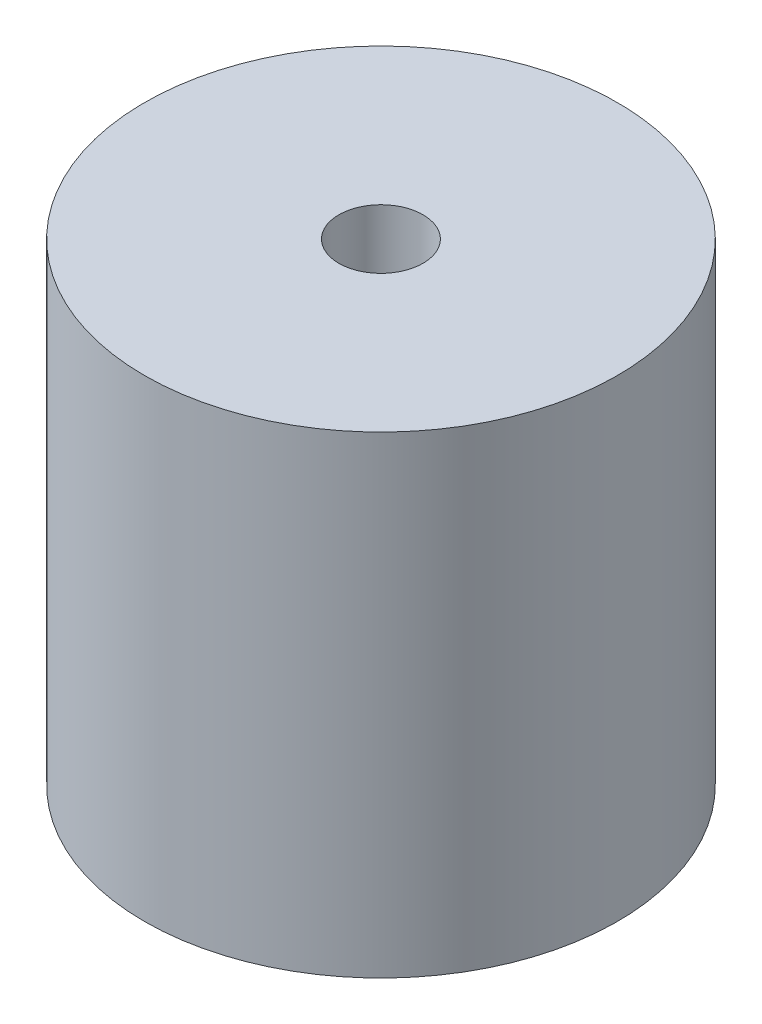
from build123d import *

# Parameters (mm, degrees)
SKETCH1_R                   = 6.35
BOSS_EXTRUDE1_DEPTH         = 12.7
F_4_40_TAPPED_HOLE1_D       = 2.2606
F_4_40_TAPPED_HOLE1_DEPTH   = 3.556
F_4_40_TAPPED_HOLE1_TIP     = 0.679152758
F_1_4_28_TAPPED_HOLE1_D     = 5.4102
F_1_4_28_TAPPED_HOLE1_DEPTH = 6
F_1_4_28_TAPPED_HOLE1_TIP   = 1.625388061


with BuildPart() as part:
    # Sketch1 → Boss-Extrude1 (new body)
    with BuildSketch(Plane(origin=(0, 0, 0), x_dir=(1, 0, 0), z_dir=(0, 1, 0))):
        Circle(SKETCH1_R)
    extrude(amount=BOSS_EXTRUDE1_DEPTH)

    # #4-40 Tapped Hole1
    with Locations(Plane(origin=(0, 12.7, 0), x_dir=(1, 0, 0), z_dir=(0, 1, 0))):
        with Locations((0, 0)):
            Hole(F_4_40_TAPPED_HOLE1_D / 2, depth=F_4_40_TAPPED_HOLE1_DEPTH)
            with Locations((0, 0, -(F_4_40_TAPPED_HOLE1_DEPTH + F_4_40_TAPPED_HOLE1_TIP / 2))):  # 118° drill point
                Cone(0, F_4_40_TAPPED_HOLE1_D / 2, F_4_40_TAPPED_HOLE1_TIP, mode=Mode.SUBTRACT)

    # 1/4-28 Tapped Hole1
    with Locations(Plane(origin=(0, 0, 0), x_dir=(-1, 0, 0), z_dir=(0, -1, 0))):
        with Locations((0, 0)):
            Hole(F_1_4_28_TAPPED_HOLE1_D / 2, depth=F_1_4_28_TAPPED_HOLE1_DEPTH)
            with Locations((0, 0, -(F_1_4_28_TAPPED_HOLE1_DEPTH + F_1_4_28_TAPPED_HOLE1_TIP / 2))):  # 118° drill point
                Cone(0, F_1_4_28_TAPPED_HOLE1_D / 2, F_1_4_28_TAPPED_HOLE1_TIP, mode=Mode.SUBTRACT)


solid = part.part
